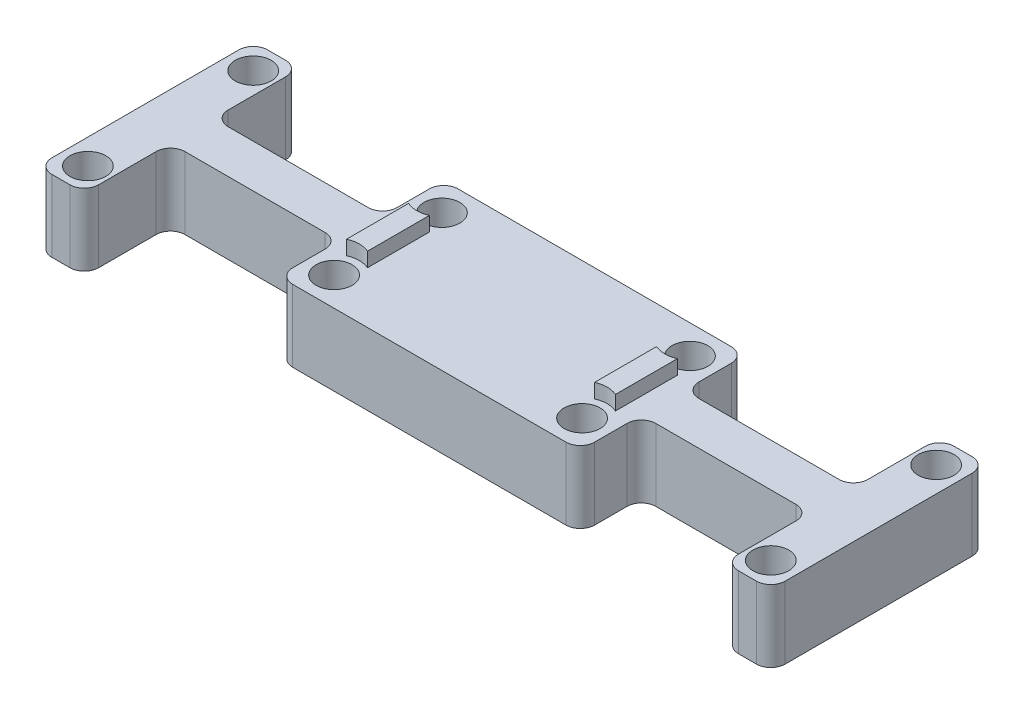
from build123d import *

# Parameters (mm, degrees)
SKETCH2_R           = 2.5
BOSS_EXTRUDE1_DEPTH = 10
BOSS_EXTRUDE2_DEPTH = 2
FILLET1_R           = 2


with BuildPart() as part:
    # Sketch2 → Boss-Extrude1 (new body)
    with BuildSketch(Plane(origin=(0, 0, 0), x_dir=(1, 0, 0), z_dir=(0, 1, 0))):
        with BuildLine():
            Line((-68.25, 22.5), (-68.25, -7.5))
            Line((-68.25, -7.5), (-61.75, -7.5))
            Line((-61.75, -7.5), (-61.75, 2.5))
            ThreePointArc((-61.75, 2.5), (-61.164213562, 3.914213562), (-59.75, 4.5))
            Line((-59.75, 4.5), (-40.25, 4.5))
            ThreePointArc((-40.25, 4.5), (-38.835786438, 3.914213562), (-38.25, 2.5))
            Line((-38.25, 2.5), (-38.25, -2))
            ThreePointArc((-38.25, -2), (-37.664213562, -3.414213562), (-36.25, -4))
            Line((-36.25, -4), (1.75, -4))
            ThreePointArc((1.75, -4), (3.164213562, -3.414213562), (3.75, -2))
            Line((3.75, -2), (3.75, 2.5))
            ThreePointArc((3.75, 2.5), (4.335786438, 3.914213562), (5.75, 4.5))
            Line((5.75, 4.5), (25.25, 4.5))
            ThreePointArc((25.25, 4.5), (26.664213562, 3.914213562), (27.25, 2.5))
            Line((27.25, 2.5), (27.25, -7.5))
            Line((27.25, -7.5), (33.75, -7.5))
            Line((33.75, -7.5), (33.75, 22.5))
            Line((33.75, 22.5), (27.25, 22.5))
            Line((27.25, 22.5), (27.25, 12.5))
            ThreePointArc((27.25, 12.5), (26.664213562, 11.085786438), (25.25, 10.5))
            Line((25.25, 10.5), (5.75, 10.5))
            ThreePointArc((5.75, 10.5), (4.335786438, 11.085786438), (3.75, 12.5))
            Line((3.75, 12.5), (3.75, 17))
            ThreePointArc((3.75, 17), (3.164213562, 18.414213562), (1.75, 19))
            Line((1.75, 19), (-36.25, 19))
            ThreePointArc((-36.25, 19), (-37.664213562, 18.414213562), (-38.25, 17))
            Line((-38.25, 17), (-38.25, 12.5))
            ThreePointArc((-38.25, 12.5), (-38.835786438, 11.085786438), (-40.25, 10.5))
            Line((-40.25, 10.5), (-59.75, 10.5))
            ThreePointArc((-59.75, 10.5), (-61.164213562, 11.085786438), (-61.75, 12.5))
            Line((-61.75, 12.5), (-61.75, 22.5))
            Line((-61.75, 22.5), (-68.25, 22.5))
        make_face()
        with Locations((-34.5, 0)):
            Circle(SKETCH2_R, mode=Mode.SUBTRACT)
        Circle(SKETCH2_R, mode=Mode.SUBTRACT)
        with Locations((-34.5, 15)):
            Circle(SKETCH2_R, mode=Mode.SUBTRACT)
        with Locations((0, 15)):
            Circle(SKETCH2_R, mode=Mode.SUBTRACT)
        with Locations((30.25, 19)):
            Circle(SKETCH2_R, mode=Mode.SUBTRACT)
        with Locations((30.25, -4)):
            Circle(SKETCH2_R, mode=Mode.SUBTRACT)
        with Locations((-64.75, -4)):
            Circle(SKETCH2_R, mode=Mode.SUBTRACT)
        with Locations((-64.75, 19)):
            Circle(SKETCH2_R, mode=Mode.SUBTRACT)
    extrude(amount=-BOSS_EXTRUDE1_DEPTH)

    # Sketch3 → Boss-Extrude2 (add)
    with BuildSketch(Plane(origin=(0, 0, 0), x_dir=(1, 0, 0), z_dir=(0, 1, 0))):
        with BuildLine():
            Line((-35.95, 11.814485913), (-35.95, 3.185514087))
            ThreePointArc((-35.95, 3.185514087), (-34.5, 3.5), (-33.05, 3.185514087))
            Line((-33.05, 3.185514087), (-33.05, 11.814485913))
            ThreePointArc((-33.05, 11.814485913), (-34.5, 11.5), (-35.95, 11.814485913))
        make_face()
        with BuildLine():
            ThreePointArc((-1.45, 3.185514087), (0, 3.5), (1.45, 3.185514087))
            Line((1.45, 3.185514087), (1.45, 11.814485913))
            ThreePointArc((1.45, 11.814485913), (0, 11.5), (-1.45, 11.814485913))
            Line((-1.45, 11.814485913), (-1.45, 3.185514087))
        make_face()
    extrude(amount=BOSS_EXTRUDE2_DEPTH)

    # Fillet1
    fillet1_edges = [part.edges().sort_by_distance(p)[0] for p in [
        (27.25, -5, -22.5),
        (33.75, -5, -22.5),
        (33.75, -5, 7.5),
        (27.25, -5, 7.5),
        (-61.75, -5, 7.5),
        (-68.25, -5, 7.5),
        (-68.25, -5, -22.5),
        (-61.75, -5, -22.5),
    ]]
    fillet(fillet1_edges, radius=FILLET1_R)


solid = part.part
